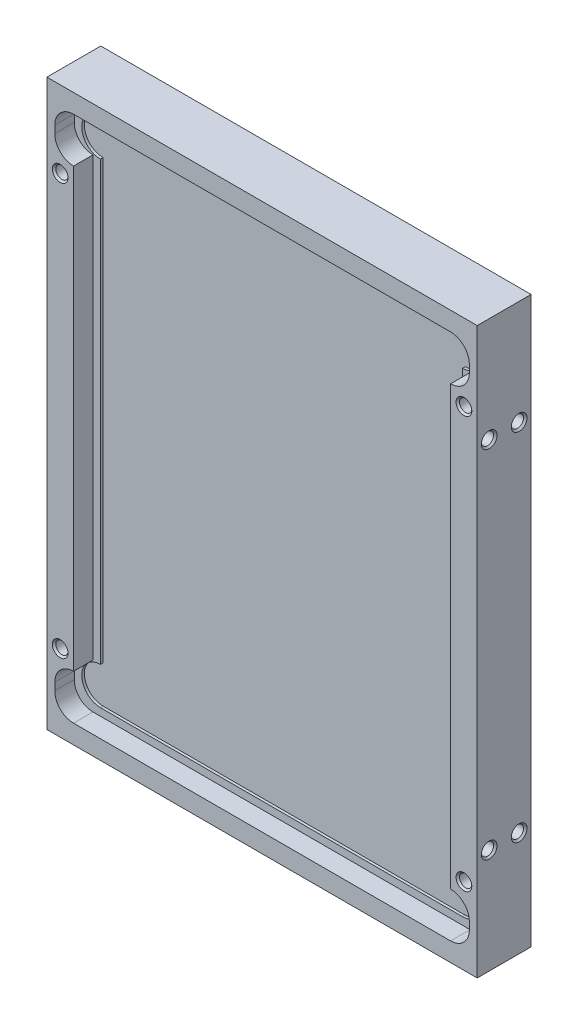
from build123d import *

# Parameters (mm, degrees)
SKETCH1_W                       = 146.05
SKETCH1_H                       = 191.77
BOSS_EXTRUDE1_DEPTH             = 9.144
CUT_EXTRUDE1_DEPTH              = 6.604
CUT_EXTRUDE3_DEPTH              = 0.889
F_8_32_TAPPED_HOLE1_AT_2_COUNT  = 2
F_8_32_TAPPED_HOLE1_AT_2_PITCH  = 137.033
F_8_32_TAPPED_HOLE1_AT_3_COUNT  = 2
F_8_32_TAPPED_HOLE1_AT_3_PITCH  = 195.688868076
F_8_32_TAPPED_HOLE1_AT_4_COUNT  = 2
F_8_32_TAPPED_HOLE1_AT_4_PITCH  = 139.7
F_8_32_TAPPED_HOLE2_D           = 4.1656
F_8_32_TAPPED_HOLE2_DEPTH       = 9.0297
F_8_32_TAPPED_HOLE2_CSINK_D     = 5.334
F_8_32_TAPPED_HOLE2_CSINK_ANGLE = 90


with BuildPart() as part:
    # Sketch1 → Boss-Extrude1 (new body, symmetric)
    with BuildSketch(Plane.XY):
        Rectangle(SKETCH1_W, SKETCH1_H)
    extrude(amount=BOSS_EXTRUDE1_DEPTH, both=True)

    # Sketch4 → Cut-Extrude1 (cut)
    with BuildSketch(Plane.XY.offset(9.144)):
        with BuildLine():
            Line((-63.9953, -74.2569), (-63.9953, 74.2569))
            ThreePointArc((-63.9953, 74.2569), (-68.485428061, 76.116771939), (-70.3453, 80.6069))
            Line((-70.3453, 80.6069), (-70.3453, 83.1469))
            ThreePointArc((-70.3453, 83.1469), (-68.485428061, 87.637028061), (-63.9953, 89.4969))
            Line((-63.9953, 89.4969), (63.9953, 89.4969))
            ThreePointArc((63.9953, 89.4969), (68.485428061, 87.637028061), (70.3453, 83.1469))
            Line((70.3453, 83.1469), (70.3453, 80.6069))
            ThreePointArc((70.3453, 80.6069), (68.485428061, 76.116771939), (63.9953, 74.2569))
            Line((63.9953, 74.2569), (63.9953, -74.2569))
            ThreePointArc((63.9953, -74.2569), (68.485428061, -76.116771939), (70.3453, -80.6069))
            Line((70.3453, -80.6069), (70.3453, -83.1469))
            ThreePointArc((70.3453, -83.1469), (68.485428061, -87.637028061), (63.9953, -89.4969))
            Line((63.9953, -89.4969), (-63.9953, -89.4969))
            ThreePointArc((-63.9953, -89.4969), (-68.485428061, -87.637028061), (-70.3453, -83.1469))
            Line((-70.3453, -83.1469), (-70.3453, -80.6069))
            ThreePointArc((-70.3453, -80.6069), (-68.485428061, -76.116771939), (-63.9953, -74.2569))
        make_face()
    cut_extrude1 = extrude(amount=-CUT_EXTRUDE1_DEPTH, mode=Mode.SUBTRACT)

    # Sketch5 → Cut-Extrude3 (cut)
    with BuildSketch(Plane(origin=(0, 0, 2.54), x_dir=(-1, 0, 0), z_dir=(0, 0, -1))):
        with BuildLine():
            Line((-61.4553, 86.9569), (61.4553, 86.9569))
            ThreePointArc((61.4553, 86.9569), (67.8053, 80.6069), (61.4553, 74.2569))
            Line((61.4553, 74.2569), (61.4553, -74.2569))
            ThreePointArc((61.4553, -74.2569), (67.8053, -80.6069), (61.4553, -86.9569))
            Line((61.4553, -86.9569), (-61.4553, -86.9569))
            ThreePointArc((-61.4553, -86.9569), (-67.8053, -80.6069), (-61.4553, -74.2569))
            Line((-61.4553, -74.2569), (-61.4553, 74.2569))
            ThreePointArc((-61.4553, 74.2569), (-67.8053, 80.6069), (-61.4553, 86.9569))
        make_face()
    cut_extrude3 = extrude(amount=CUT_EXTRUDE3_DEPTH, mode=Mode.SUBTRACT)

    # Mirror1: Cut-Extrude1, Cut-Extrude3 across plane
    add(cut_extrude1.mirror(Plane.XY), mode=Mode.SUBTRACT)
    add(cut_extrude3.mirror(Plane.XY), mode=Mode.SUBTRACT)

    # Sketch8 → #8-32 Tapped Hole1 (revolve, cut)
    with BuildSketch(Plane(origin=(68.5165, 69.85, 9.144), x_dir=(0, -1, 0), z_dir=(1, 0, 0))):
        Polygon((0, 0), (0, 18.288), (2.667, 18.288), (2.0828, 17.7038), (2.0828, 0.5842), (2.667, 0), align=None)
    f_8_32_tapped_hole1 = revolve(axis=Axis((68.5165, 69.85, 15.494), (0, 0, -1)), mode=Mode.SUBTRACT)

    # #8-32 Tapped Hole1 at 2: #8-32 Tapped Hole1 ×2
    with Locations(*[(-i * F_8_32_TAPPED_HOLE1_AT_2_PITCH, 0, 0) for i in range(1, F_8_32_TAPPED_HOLE1_AT_2_COUNT)]):
        add(f_8_32_tapped_hole1, mode=Mode.SUBTRACT)

    # #8-32 Tapped Hole1 at 3: #8-32 Tapped Hole1 ×2
    with Locations(*[Vector(-0.700259557, -0.713888334, 0) * (i * F_8_32_TAPPED_HOLE1_AT_3_PITCH) for i in range(1, F_8_32_TAPPED_HOLE1_AT_3_COUNT)]):
        add(f_8_32_tapped_hole1, mode=Mode.SUBTRACT)

    # #8-32 Tapped Hole1 at 4: #8-32 Tapped Hole1 ×2
    with Locations(*[(0, -i * F_8_32_TAPPED_HOLE1_AT_4_PITCH, 0) for i in range(1, F_8_32_TAPPED_HOLE1_AT_4_COUNT)]):
        add(f_8_32_tapped_hole1, mode=Mode.SUBTRACT)

    # #8-32 Tapped Hole2
    with Locations(Plane(origin=(73.025, 0, 0), x_dir=(0, 0, -1), z_dir=(1, 0, 0))):
        with Locations((5.08, 60.325), (-5.08, -60.325), (5.08, -60.325), (-5.08, 60.325)):
            CounterSinkHole(F_8_32_TAPPED_HOLE2_D / 2, F_8_32_TAPPED_HOLE2_CSINK_D / 2, depth=F_8_32_TAPPED_HOLE2_DEPTH, counter_sink_angle=F_8_32_TAPPED_HOLE2_CSINK_ANGLE)


solid = part.part
